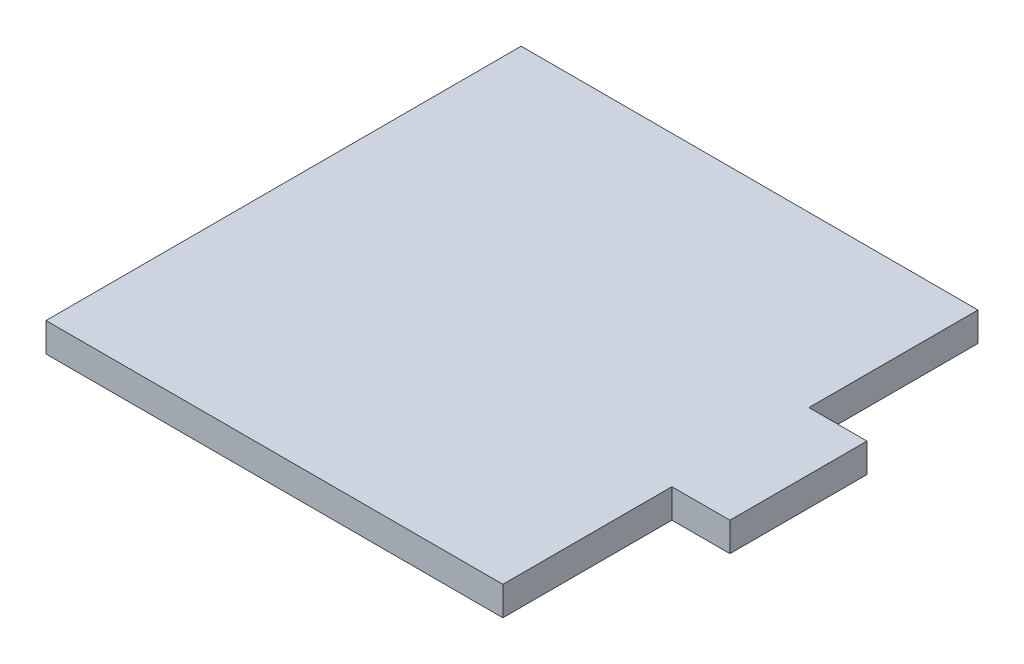
from build123d import *

# Parameters (mm, degrees)
BOSS_EXTRUDE1_DEPTH = 3.175


with BuildPart() as part:
    # Sketch1 → Boss-Extrude1 (new body)
    with BuildSketch(Plane(origin=(0, 0, 0), x_dir=(1, 0, 0), z_dir=(0, 1, 0))):
        Polygon((-25, 0), (-25, 18.5), (25, 18.5), (25, 0), (31.35, 0), (31.35, -15), (25, -15), (25, -33.5), (-25, -33.5), (-25, -15), align=None)
    extrude(amount=BOSS_EXTRUDE1_DEPTH)


solid = part.part
